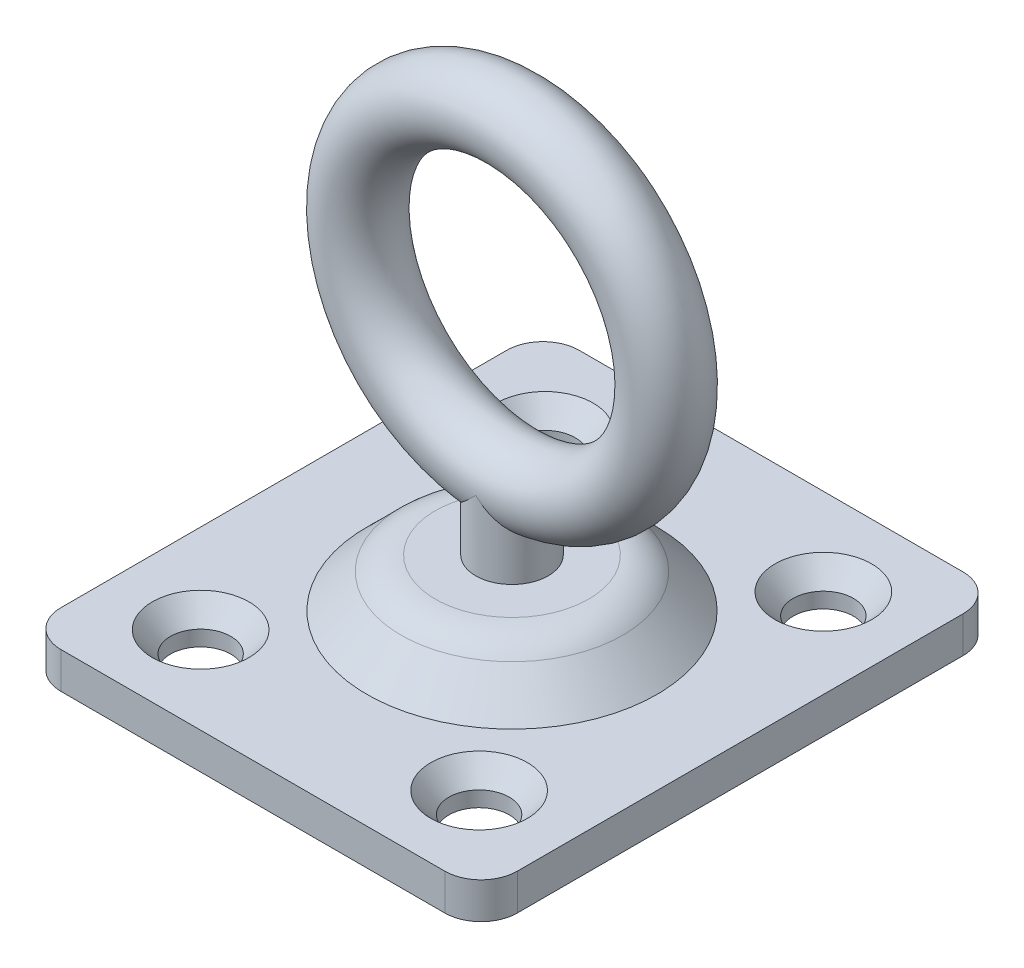
from build123d import *

# Parameters (mm, degrees)
BOSS_EXTRUDE1_DEPTH = 2.38125
CUT_EXTRUDE1_REACH  = 24.801
SKETCH2_R           = 1.984375
SKETCH6_R           = 4.7625
SKETCH6_R_2         = 2.38125
BOSS_EXTRUDE2_DEPTH = 1.190625
SKETCH9_R           = 2.38125


with BuildPart() as part:
    # Sketch1 → Boss-Extrude1 (new body)
    with BuildSketch(Plane(origin=(0, 0, 0), x_dir=(1, 0, 0), z_dir=(0, 1, 0))):
        with BuildLine():
            Line((-12.60475, 17.018), (12.60475, 17.018))
            ThreePointArc((12.60475, 17.018), (14.288548023, 16.320548023), (14.986, 14.63675))
            Line((14.986, 14.63675), (14.986, -14.63675))
            ThreePointArc((14.986, -14.63675), (14.288548023, -16.320548023), (12.60475, -17.018))
            Line((12.60475, -17.018), (-12.60475, -17.018))
            ThreePointArc((-12.60475, -17.018), (-14.288548023, -16.320548023), (-14.986, -14.63675))
            Line((-14.986, -14.63675), (-14.986, 14.63675))
            ThreePointArc((-14.986, 14.63675), (-14.288548023, 16.320548023), (-12.60475, 17.018))
        make_face()
    extrude(amount=BOSS_EXTRUDE1_DEPTH)

    # Sketch2 → Cut-Extrude1 (cut, up to next)
    with BuildSketch(Plane(origin=(0, 0, 0), x_dir=(1, 0, 0), z_dir=(0, 1, 0)), mode=Mode.PRIVATE) as cut_extrude1_sk1:
        with Locations(Location((-9.144, 11.303, 0), (0, 0, 270))):
            Circle(SKETCH2_R)
    cut_extrude1_tool1 = extrude(cut_extrude1_sk1.sketch, amount=CUT_EXTRUDE1_REACH, mode=Mode.PRIVATE) & part.part
    # Sketch2 → Cut-Extrude1 (cut, up to next)
    with BuildSketch(Plane(origin=(0, 0, 0), x_dir=(1, 0, 0), z_dir=(0, 1, 0)), mode=Mode.PRIVATE) as cut_extrude1_sk2:
        with Locations(Location((9.144, 11.303, 0), (0, 0, 270))):
            Circle(SKETCH2_R)
    cut_extrude1_tool2 = extrude(cut_extrude1_sk2.sketch, amount=CUT_EXTRUDE1_REACH, mode=Mode.PRIVATE) & part.part
    # Sketch2 → Cut-Extrude1 (cut, up to next)
    with BuildSketch(Plane(origin=(0, 0, 0), x_dir=(1, 0, 0), z_dir=(0, 1, 0)), mode=Mode.PRIVATE) as cut_extrude1_sk3:
        with Locations(Location((9.144, -11.303, 0), (0, 0, 270))):
            Circle(SKETCH2_R)
    cut_extrude1_tool3 = extrude(cut_extrude1_sk3.sketch, amount=CUT_EXTRUDE1_REACH, mode=Mode.PRIVATE) & part.part
    # Sketch2 → Cut-Extrude1 (cut, up to next)
    with BuildSketch(Plane(origin=(0, 0, 0), x_dir=(1, 0, 0), z_dir=(0, 1, 0)), mode=Mode.PRIVATE) as cut_extrude1_sk4:
        with Locations(Location((-9.144, -11.303, 0), (0, 0, 270))):
            Circle(SKETCH2_R)
    cut_extrude1_tool4 = extrude(cut_extrude1_sk4.sketch, amount=CUT_EXTRUDE1_REACH, mode=Mode.PRIVATE) & part.part
    add(cut_extrude1_tool1.solids().sort_by_distance((-9.144, 0, -11.303))[0], mode=Mode.SUBTRACT)
    add(cut_extrude1_tool2.solids().sort_by_distance((9.144, 0, -11.303))[0], mode=Mode.SUBTRACT)
    add(cut_extrude1_tool3.solids().sort_by_distance((9.144, 0, 11.303))[0], mode=Mode.SUBTRACT)
    add(cut_extrude1_tool4.solids().sort_by_distance((-9.144, 0, 11.303))[0], mode=Mode.SUBTRACT)

    # Cut-Extrude2 cone 1 section (through the dimple's axis) → Cut-Extrude2 (revolve, cut)
    with BuildSketch(Plane(origin=(-9.144, 2.38125, -11.303), x_dir=(0, 0, 1), z_dir=(1, 0, 0))):
        Polygon((0, 0), (3.175, 0), (0, 3.652419693), align=None)
    revolve(axis=Axis((-9.144, 2.38125, -11.303), (0, -1, 0)), mode=Mode.SUBTRACT)

    # Cut-Extrude2 cone 2 section (through the dimple's axis) → Cut-Extrude2 cone 2 (revolve, cut)
    with BuildSketch(Plane(origin=(9.144, 2.38125, -11.303), x_dir=(0, 0, 1), z_dir=(1, 0, 0))):
        Polygon((0, 0), (3.175, 0), (0, 3.652419693), align=None)
    revolve(axis=Axis((9.144, 2.38125, -11.303), (0, -1, 0)), mode=Mode.SUBTRACT)

    # Cut-Extrude2 cone 3 section (through the dimple's axis) → Cut-Extrude2 cone 3 (revolve, cut)
    with BuildSketch(Plane(origin=(9.144, 2.38125, 11.303), x_dir=(0, 0, 1), z_dir=(1, 0, 0))):
        Polygon((0, 0), (3.175, 0), (0, 3.652419693), align=None)
    revolve(axis=Axis((9.144, 2.38125, 11.303), (0, -1, 0)), mode=Mode.SUBTRACT)

    # Cut-Extrude2 cone 4 section (through the dimple's axis) → Cut-Extrude2 cone 4 (revolve, cut)
    with BuildSketch(Plane(origin=(-9.144, 2.38125, 11.303), x_dir=(0, 0, 1), z_dir=(1, 0, 0))):
        Polygon((0, 0), (3.175, 0), (0, 3.652419693), align=None)
    revolve(axis=Axis((-9.144, 2.38125, 11.303), (0, -1, 0)), mode=Mode.SUBTRACT)

    # Sketch4 → Revolve1 (revolve)
    with BuildSketch(Plane.XY, mode=Mode.PRIVATE) as revolve1_sk:
        with BuildLine():
            Line((-9.525, 2.38125), (-7.27993597, 4.62631403))
            ThreePointArc((-7.27993597, 4.62631403), (-6.249891837, 5.314567516), (-5.034871939, 5.55625))
            Line((-5.034871939, 5.55625), (0, 5.55625))
            Line((0, 5.55625), (0, 2.38125))
            Line((0, 2.38125), (-9.525, 2.38125))
        make_face()
    revolve(revolve1_sk.sketch.rotate(Axis((0, 0, 0), (0, 1, 0)), 270), axis=Axis((0, 0, 0), (0, 1, 0)))

    # Sketch5 → Cut-Revolve1 (revolve, cut)
    with BuildSketch(Plane.XY, mode=Mode.PRIVATE) as cut_revolve1_sk:
        with BuildLine():
            Line((0, 5.55625), (-2.38125, 5.55625))
            Line((-2.38125, 5.55625), (-2.38125, 3.175))
            Line((-2.38125, 3.175), (-5.034871939, 3.175))
            ThreePointArc((-5.034871939, 3.175), (-5.338626914, 3.114579379), (-5.596137947, 2.942516008))
            Line((-5.596137947, 2.942516008), (-7.841201977, 0.697451977))
            ThreePointArc((-7.841201977, 0.697451977), (-8.613735077, 0.181261863), (-9.525, 0))
            Line((-9.525, 0), (0, 0))
            Line((0, 0), (0, 5.55625))
        make_face()
    revolve(cut_revolve1_sk.sketch.rotate(Axis((0, 32.766, 0), (0, -1, 0)), 270), axis=Axis((0, 32.766, 0), (0, -1, 0)), mode=Mode.SUBTRACT)


with BuildPart() as body_2:
    # Sketch6 → Boss-Extrude2 (new body)
    with BuildSketch(Plane.XZ.offset(-3.175)):
        with Locations(Location((0, 0, 0), (0, 0, 90))):
            Circle(SKETCH6_R)
        with Locations(Location((0, 0, 0), (0, 0, 90))):
            Circle(SKETCH6_R_2, mode=Mode.SUBTRACT)
    extrude(amount=BOSS_EXTRUDE2_DEPTH)


with BuildPart() as body_3:
    # Sketch7 → Revolve2 (revolve)
    with BuildSketch(Plane.XY, mode=Mode.PRIVATE) as revolve2_sk:
        with BuildLine():
            Line((-2.38125, 10.12825), (-2.38125, 1.984375))
            Line((-2.38125, 1.984375), (-3.175, 1.984375))
            ThreePointArc((-3.175, 1.984375), (-1.695450743, 1.101193851), (0, 0.79375))
            Line((0, 0.79375), (0, 10.12825))
            Line((0, 10.12825), (-2.38125, 10.12825))
        make_face()
    revolve(revolve2_sk.sketch.rotate(Axis((0, 32.766, 0), (0, -1, 0)), 270), axis=Axis((0, 32.766, 0), (0, -1, 0)))

    # Sweep1: sweep along a path in Sketch8
    with BuildLine(Plane.XY) as sweep1_path:
        CenterArc((0, 20.2565), 10.12825, 0, 360)
    # Sketch9 → Sweep1 (sweep)
    with BuildSketch(Plane(origin=(0, 0, 0), x_dir=(0, 0, -1), z_dir=(1, 0, 0))):
        with Locations((0, 30.38475)):
            Circle(SKETCH9_R)
    sweep(path=sweep1_path.line)


solid = Compound([part.part, body_2.part, body_3.part])
